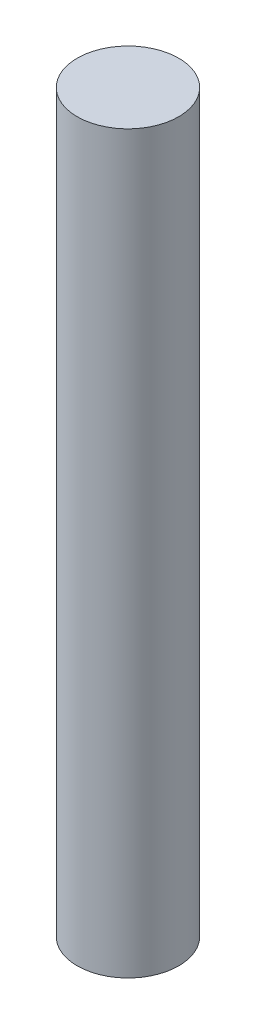
from build123d import *

# Parameters (mm, degrees)
SKETCH1_R           = 1.7526
BOSS_EXTRUDE1_DEPTH = 25.4


with BuildPart() as part:
    # Sketch1 → Boss-Extrude1 (new body)
    with BuildSketch(Plane(origin=(0, 0, 0), x_dir=(1, 0, 0), z_dir=(0, 1, 0))):
        Circle(SKETCH1_R)
    extrude(amount=BOSS_EXTRUDE1_DEPTH)


solid = part.part
